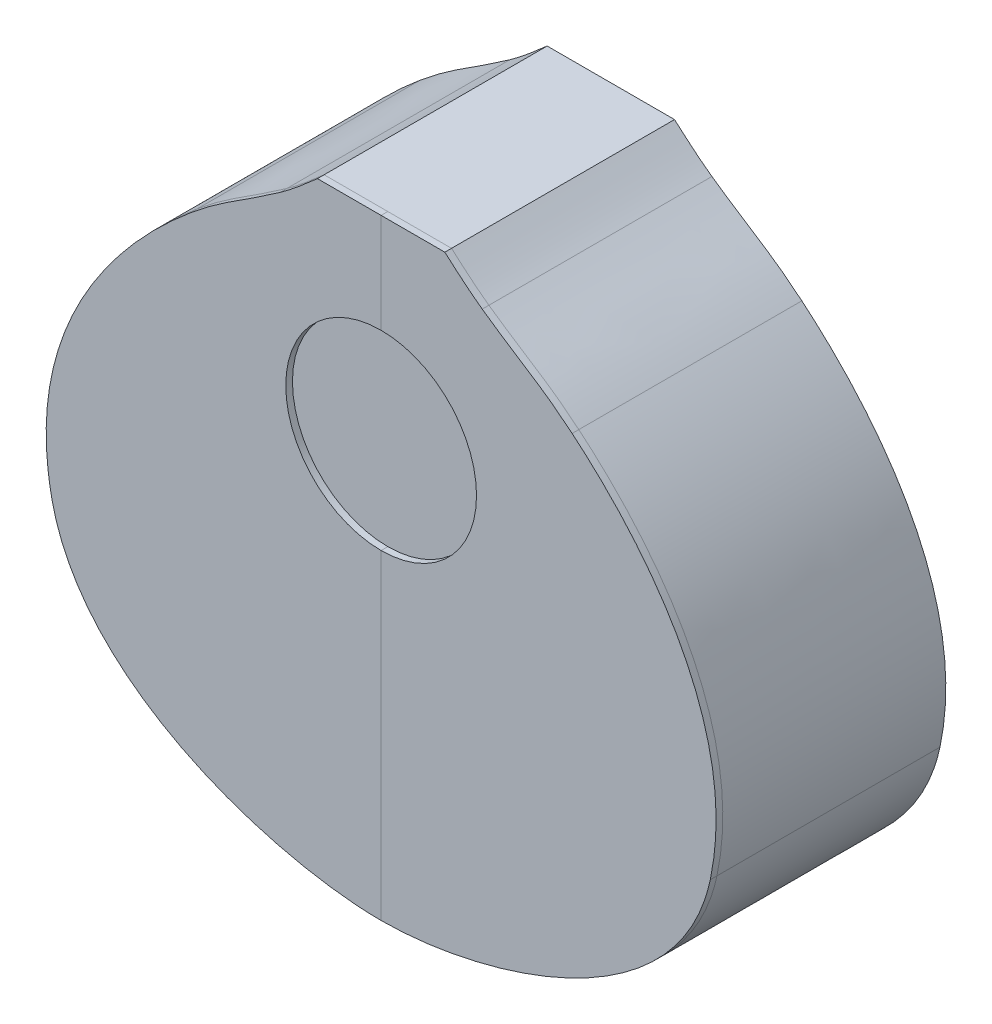
from build123d import *

# Parameters (mm, degrees)
SALIENTE_EXTRUIR1_DEPTH = 100
SALIENTE_EXTRUIR2_DEPTH = 100
SALIENTE_EXTRUIR6_DEPTH = 3
SALIENTE_EXTRUIR7_DEPTH = 3


with BuildPart() as part:
    # Croquis1 → Saliente-Extruir1 (new body)
    with BuildSketch(Plane.XY):
        with BuildLine():
            Line((-28.560802162, 136.916395712), (2.54e-07, 136.916395712))
            Line((2.54e-07, 136.916395712), (2.54e-07, -136.916395712))
            add(Edge.make_bspline(
                [(2.54e-07, -136.916395712), (-46.441340442, -136.916395602), (-133.83340639, -111.670406771), (-147.578497366, -47.27649641)],
                knots=[0, 0, 0, 0, 1, 1, 1, 1], degree=3))
            add(Edge.make_bspline(
                [(-147.578497366, -47.27649641), (-163.110192587, 25.487257565), (-105.360717743, 78.580885367), (-85.639397682, 95.058759336)],
                knots=[0, 0, 0, 0, 1, 1, 1, 1], degree=3))
            add(Edge.make_bspline(
                [(-85.639397682, 95.058759336), (-70.778695882, 107.475422336), (-62.78576597, 110.83954464), (-45.323206026, 123.188624336)],
                knots=[0, 0, 0, 0, 1, 1, 1, 1], degree=3))
            add(Edge.make_bspline(
                [(-45.323206026, 123.188624336), (-39.50234289, 127.304974752), (-33.933522938, 132.194713512), (-28.560802162, 136.916395712)],
                knots=[0, 0, 0, 0, 1, 1, 1, 1], degree=3))
        make_face()
    extrude(amount=SALIENTE_EXTRUIR1_DEPTH)

    # Croquis3 → Saliente-Extruir2 (add)
    with BuildSketch(Plane.XY):
        with BuildLine():
            Line((2.54e-07, 136.916395712), (0, -136.916395712))
            add(Edge.make_bspline(
                [(0, -136.916395712), (46.441340696, -136.916395629), (133.833406659, -111.67040685), (147.578497673, -47.276496498)],
                knots=[0, 0, 0, 0, 1, 1, 1, 1], degree=3))
            add(Edge.make_bspline(
                [(147.578497673, -47.276496498), (163.110192997, 25.487257456), (105.360718228, 78.58088534), (85.63939819, 95.058759336)],
                knots=[0, 0, 0, 0, 1, 1, 1, 1], degree=3))
            add(Edge.make_bspline(
                [(85.63939819, 95.058759336), (70.77869639, 107.475422336), (62.785766478, 110.83954464), (45.323206534, 123.188624336)],
                knots=[0, 0, 0, 0, 1, 1, 1, 1], degree=3))
            add(Edge.make_bspline(
                [(45.323206534, 123.188624336), (39.502343398, 127.304974752), (33.933523446, 132.194713512), (28.56080267, 136.916395712)],
                knots=[0, 0, 0, 0, 1, 1, 1, 1], degree=3))
            Line((28.56080267, 136.916395712), (2.54e-07, 136.916395712))
        make_face()
    extrude(amount=SALIENTE_EXTRUIR2_DEPTH)


with BuildPart() as body_2:
    # Croquis10 → Saliente-Extruir6 (new body)
    with BuildSketch(Plane.XY.offset(100)):
        with BuildLine():
            Line((-28.560802162, 136.916395712), (2.54e-07, 136.916395712))
            Line((2.54e-07, 136.916395712), (2.54e-07, 92.306545302))
            ThreePointArc((2.54e-07, 92.306545302), (-42.768313835, 49.538231213), (2.54e-07, 6.769917124))
            Line((2.54e-07, 6.769917124), (2.54e-07, -136.916395712))
            add(Edge.make_bspline(
                [(2.54e-07, -136.916395712), (-46.441340442, -136.916395602), (-133.83340639, -111.670406771), (-147.578497366, -47.27649641)],
                knots=[0, 0, 0, 0, 1, 1, 1, 1], degree=3))
            add(Edge.make_bspline(
                [(-147.578497366, -47.27649641), (-163.110192587, 25.487257565), (-105.360717743, 78.580885367), (-85.639397682, 95.058759336)],
                knots=[0, 0, 0, 0, 1, 1, 1, 1], degree=3))
            add(Edge.make_bspline(
                [(-85.639397682, 95.058759336), (-70.778695882, 107.475422336), (-62.78576597, 110.83954464), (-45.323206026, 123.188624336)],
                knots=[0, 0, 0, 0, 1, 1, 1, 1], degree=3))
            add(Edge.make_bspline(
                [(-45.323206026, 123.188624336), (-39.50234289, 127.304974752), (-33.933522938, 132.194713512), (-28.560802162, 136.916395712)],
                knots=[0, 0, 0, 0, 1, 1, 1, 1], degree=3))
        make_face()
    extrude(amount=SALIENTE_EXTRUIR6_DEPTH)


with BuildPart() as body_3:
    # Croquis8 → Saliente-Extruir7 (new body)
    with BuildSketch(Plane.XY.offset(100)):
        with BuildLine():
            Line((2.54e-07, 6.769917124), (2.54e-07, -136.916395712))
            add(Edge.make_bspline(
                [(2.54e-07, -136.916395712), (46.44134095, -136.916395602), (133.833406898, -111.670406771), (147.578497874, -47.27649641)],
                knots=[0, 0, 0, 0, 1, 1, 1, 1], degree=3))
            add(Edge.make_bspline(
                [(147.578497874, -47.27649641), (163.110193095, 25.487257565), (105.360718251, 78.580885367), (85.63939819, 95.058759336)],
                knots=[0, 0, 0, 0, 1, 1, 1, 1], degree=3))
            add(Edge.make_bspline(
                [(85.63939819, 95.058759336), (70.77869639, 107.475422336), (62.785766478, 110.83954464), (45.323206534, 123.188624336)],
                knots=[0, 0, 0, 0, 1, 1, 1, 1], degree=3))
            add(Edge.make_bspline(
                [(45.323206534, 123.188624336), (39.502343398, 127.304974752), (33.933523446, 132.194713512), (28.56080267, 136.916395712)],
                knots=[0, 0, 0, 0, 1, 1, 1, 1], degree=3))
            Line((28.56080267, 136.916395712), (2.54e-07, 136.916395712))
            Line((2.54e-07, 136.916395712), (2.54e-07, 92.306545302))
            ThreePointArc((2.54e-07, 92.306545302), (42.768314343, 49.538231213), (2.54e-07, 6.769917124))
        make_face()
    extrude(amount=SALIENTE_EXTRUIR7_DEPTH)


solid = Compound([part.part, body_2.part, body_3.part])
